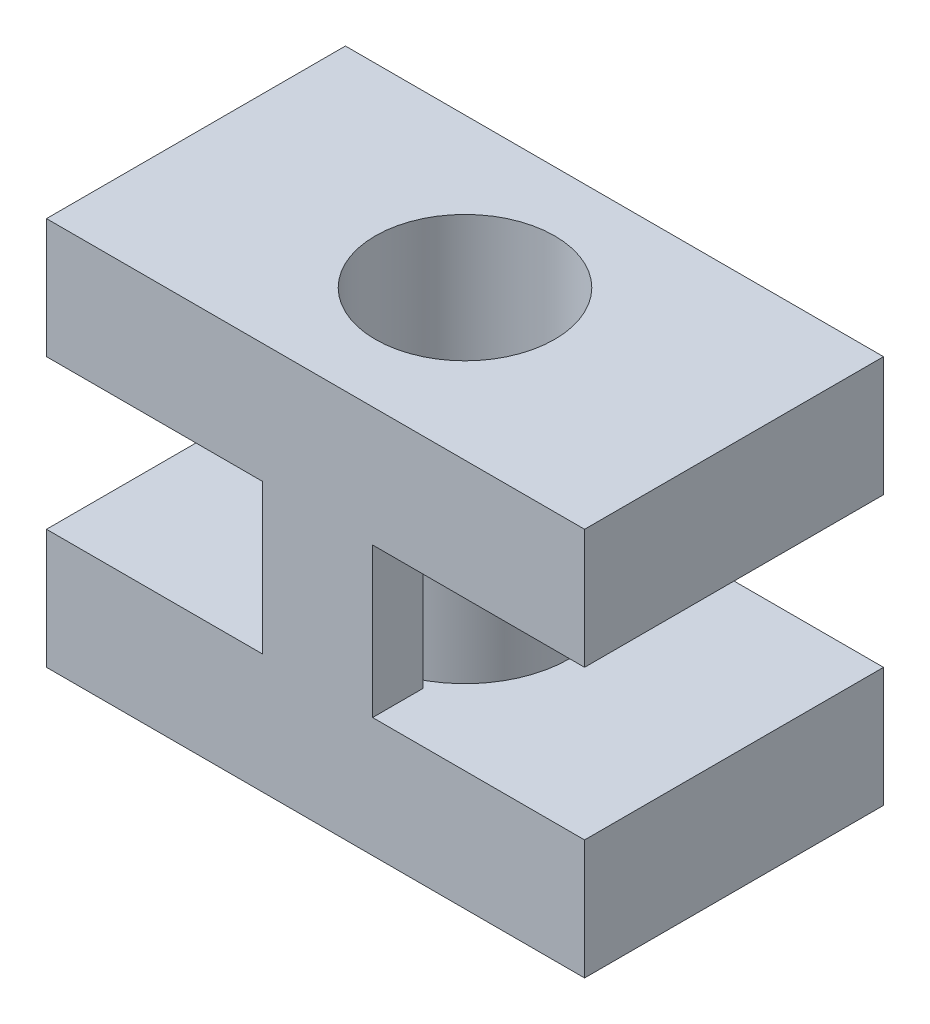
from build123d import *

# Parameters (mm, degrees)
SKETCH1_R           = 1.75
SKETCH1_R_2         = 1.5
BOSS_EXTRUDE1_DEPTH = 3.25
SKETCH2_W           = 9
SKETCH2_H           = 5
SKETCH2_R           = 1.5
BOSS_EXTRUDE2_DEPTH = 2
BOSS_EXTRUDE3_DEPTH = 2.5


with BuildPart() as part:
    # Sketch1 → Boss-Extrude1 (new body, symmetric)
    with BuildSketch(Plane(origin=(0, 0, 0), x_dir=(1, 0, 0), z_dir=(0, 1, 0))):
        Circle(SKETCH1_R)
        Circle(SKETCH1_R_2, mode=Mode.SUBTRACT)
    extrude(amount=BOSS_EXTRUDE1_DEPTH, both=True)

    # Sketch2 → Boss-Extrude2 (add)
    with BuildSketch(Plane(origin=(0, 3.25, 0), x_dir=(1, 0, 0), z_dir=(0, 1, 0))):
        Rectangle(SKETCH2_W, SKETCH2_H)
        Circle(SKETCH2_R, mode=Mode.SUBTRACT)
    boss_extrude2 = extrude(amount=-BOSS_EXTRUDE2_DEPTH)

    # Mirror1: Boss-Extrude2 across plane
    add(boss_extrude2.mirror(Plane.ZX))

    # Sketch3 → Boss-Extrude3 (add)
    with BuildSketch(Plane(origin=(0, -1.25, 0), x_dir=(1, 0, 0), z_dir=(0, 1, 0))):
        Polygon((0, 1.657655202), (-0.890187657, 1.657655202), (-0.890187657, 2.5), (0.95442496, 2.5), (0.95442496, 1.657655202), align=None)
        Polygon((0.95442496, -1.657655202), (0, -1.657655202), (-0.890187657, -1.657655202), (-0.890187657, -2.5), (0.95442496, -2.5), align=None)
    extrude(amount=BOSS_EXTRUDE3_DEPTH)


solid = part.part
